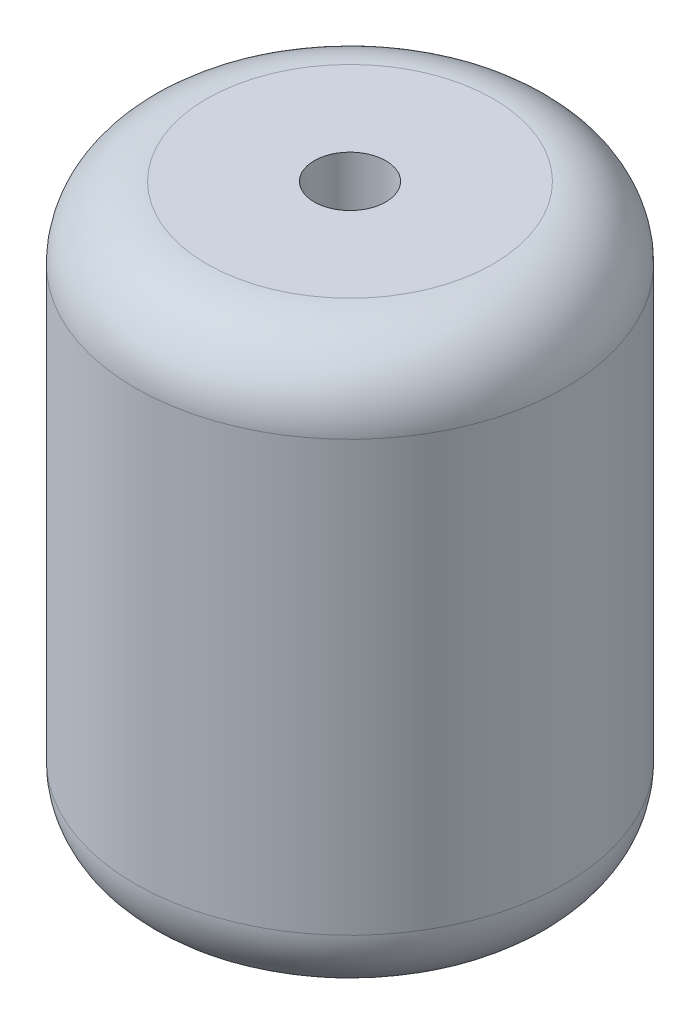
from build123d import *

# Parameters (mm, degrees)
SKETCH_1_R      = 3
SKETCH_1_R_2    = 0.5
EXTRUDE_1_DEPTH = 8
FILLET_1_R      = 1


with BuildPart() as part:
    # 草图1 → 凸台-拉伸1 (new body)
    with BuildSketch(Plane(origin=(0, 0, 0), x_dir=(1, 0, 0), z_dir=(0, 1, 0))):
        Circle(SKETCH_1_R)
        Circle(SKETCH_1_R_2, mode=Mode.SUBTRACT)
    extrude(amount=EXTRUDE_1_DEPTH)

    # 圆角1
    fillet_1_edges = [part.edges().sort_by_distance(p)[0] for p in [
        (-3, 0, 0),
        (-3, 8, 0),
    ]]
    fillet(fillet_1_edges, radius=FILLET_1_R)


solid = part.part
